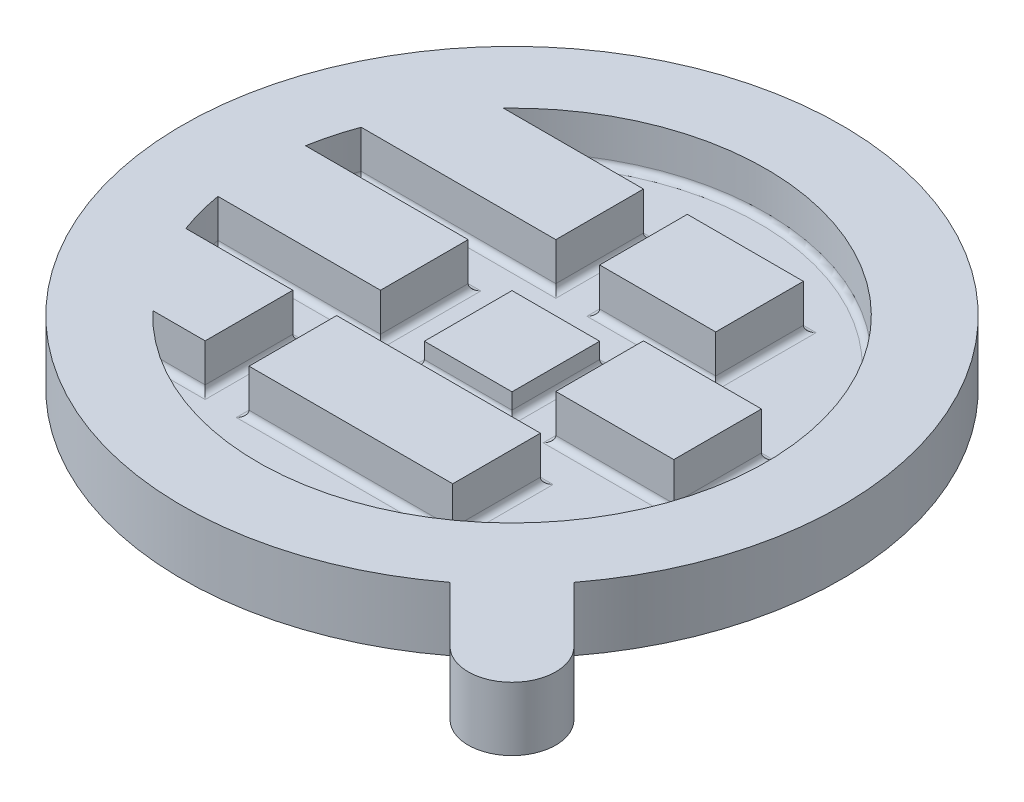
from build123d import *

# Parameters (mm, degrees)
BOSS_EXTRUDE12_DEPTH = 3
SKETCH1_16_W         = 18.27
SKETCH1_16_H         = 13.8
SKETCH1_16_W_2       = 18.57
SKETCH1_16_W_3       = 32.07
BOSS_EXTRUDE13_DEPTH = 10
SKETCH1_17_W         = 13.8
SKETCH1_17_H         = 13.8
BOSS_EXTRUDE14_DEPTH = 6.5
FILLET1_R            = 1


with BuildPart() as part:
    # Sketch1 → Boss-Extrude12 (new body)
    with BuildSketch(Plane(origin=(0, 0, 0), x_dir=(1, 0, 0), z_dir=(0, 1, 0))):
        with BuildLine():
            Line((81.494030169, 8.747896251), (90.24192642, 0))
            ThreePointArc((90.24192642, 0), (100, 0), (100, 9.75807358))
            Line((100, 9.75807358), (91.252103749, 18.505969831))
            ThreePointArc((91.252103749, 18.505969831), (13.301158056, 86.698841944), (81.494030169, 8.747896251))
        make_face()
    extrude(amount=BOSS_EXTRUDE12_DEPTH)

    # Sketch1_16 → Boss-Extrude13 (add)
    # profile 1 of 4: a face of its own
    with BuildSketch(Plane(origin=(0, 0, 0), x_dir=(1, 0, 0), z_dir=(0, 1, 0))):
        with BuildLine():
            Line((81.494030169, 8.747896251), (90.24192642, 0))
            ThreePointArc((90.24192642, 0), (100, 0), (100, 9.75807358))
            Line((100, 9.75807358), (91.252103749, 18.505969831))
            ThreePointArc((91.252103749, 18.505969831), (13.301158056, 86.698841944), (81.494030169, 8.747896251))
        make_face()
        with BuildLine():
            Line((21.047625313, 22.4), (29.3, 22.4))
            Line((29.3, 22.4), (29.3, 36.2))
            Line((29.3, 36.2), (12.455892606, 36.2))
            ThreePointArc((12.455892606, 36.2), (11.37337625, 39.608467983), (10.599619291, 43.1))
            Line((10.599619291, 43.1), (36.2, 43.1))
            Line((36.2, 43.1), (36.2, 56.9))
            Line((36.2, 56.9), (10.599619291, 56.9))
            ThreePointArc((10.599619291, 56.9), (11.37337625, 60.391532017), (12.455892606, 63.8))
            Line((12.455892606, 63.8), (43.1, 63.8))
            Line((43.1, 63.8), (43.1, 77.6))
            Line((43.1, 77.6), (21.047625313, 77.6))
            ThreePointArc((21.047625313, 77.6), (90, 50), (21.047625313, 22.4))
        make_face(mode=Mode.SUBTRACT)
    # profile 2 of 4: a face of its own
    with BuildSketch(Plane(origin=(0, 0, 0), x_dir=(1, 0, 0), z_dir=(0, 1, 0))):
        with Locations((59.135, 70.7)):
            Rectangle(SKETCH1_16_W, SKETCH1_16_H)
    # profile 3 of 4: a face of its own
    with BuildSketch(Plane(origin=(0, 0, 0), x_dir=(1, 0, 0), z_dir=(0, 1, 0))):
        with Locations((73.085, 50)):
            Rectangle(SKETCH1_16_W_2, SKETCH1_16_H)
    # profile 4 of 4: a face of its own
    with BuildSketch(Plane(origin=(0, 0, 0), x_dir=(1, 0, 0), z_dir=(0, 1, 0))):
        with Locations((52.235, 29.3)):
            Rectangle(SKETCH1_16_W_3, SKETCH1_16_H)
    extrude(amount=BOSS_EXTRUDE13_DEPTH)

    # Sketch1_17 → Boss-Extrude14 (add)
    with BuildSketch(Plane(origin=(0, 0, 0), x_dir=(1, 0, 0), z_dir=(0, 1, 0))):
        with Locations((50, 50)):
            Rectangle(SKETCH1_17_W, SKETCH1_17_H)
    extrude(amount=BOSS_EXTRUDE14_DEPTH)

    # Fillet1
    fillet1_edges = [part.edges().sort_by_distance(p)[0] for p in [
        (90, 3, -50),
        (36.2, 3, -29.3),
        (52.235, 3, -22.4),
        (50, 3, -70.7),
        (59.135, 3, -63.8),
        (43.1, 3, -50),
        (50, 3, -43.1),
        (63.8, 3, -50),
        (73.085, 3, -43.1),
        (50, 3, -56.9),
        (73.085, 3, -56.9),
        (56.9, 3, -50),
        (52.235, 3, -36.2),
        (68.27, 3, -29.3),
        (82.37, 3, -50),
        (68.27, 3, -70.7),
        (59.135, 3, -77.6),
        (32.073812657, 3, -77.6),
        (43.1, 3, -70.7),
        (27.777946303, 3, -63.8),
        (11.37337625, 3, -60.391532017),
        (23.399809646, 3, -56.9),
        (36.2, 3, -50),
        (23.399809646, 3, -43.1),
        (11.37337625, 3, -39.608467983),
        (20.877946303, 3, -36.2),
        (29.3, 3, -29.3),
        (25.173812657, 3, -22.4),
    ]]
    fillet(fillet1_edges, radius=FILLET1_R)


solid = part.part
